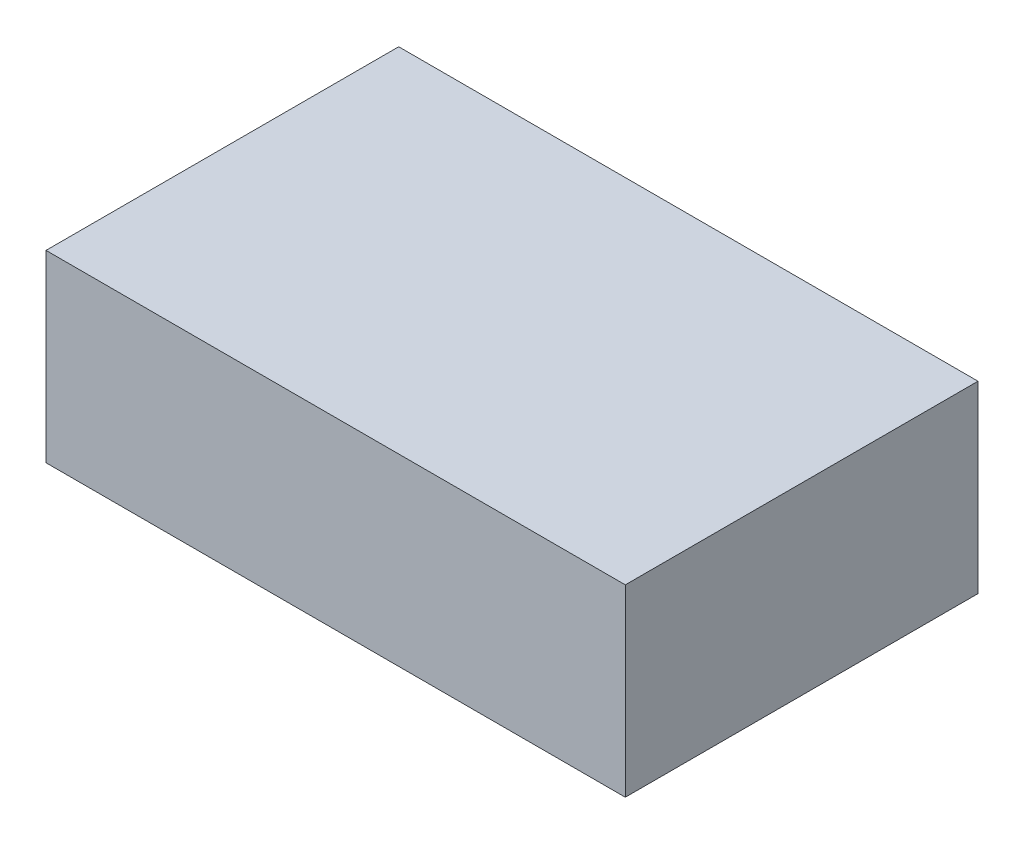
from build123d import *

# Parameters (mm, degrees)
SKETCH1_W           = 159.974379678
SKETCH1_H           = 97.39372856
BOSS_EXTRUDE2_DEPTH = 50.8


with BuildPart() as part:
    # Sketch1 → Boss-Extrude2 (new body)
    with BuildSketch(Plane(origin=(0, 0, 0), x_dir=(1, 0, 0), z_dir=(0, 1, 0))):
        Rectangle(SKETCH1_W, SKETCH1_H)
    extrude(amount=BOSS_EXTRUDE2_DEPTH)


solid = part.part
